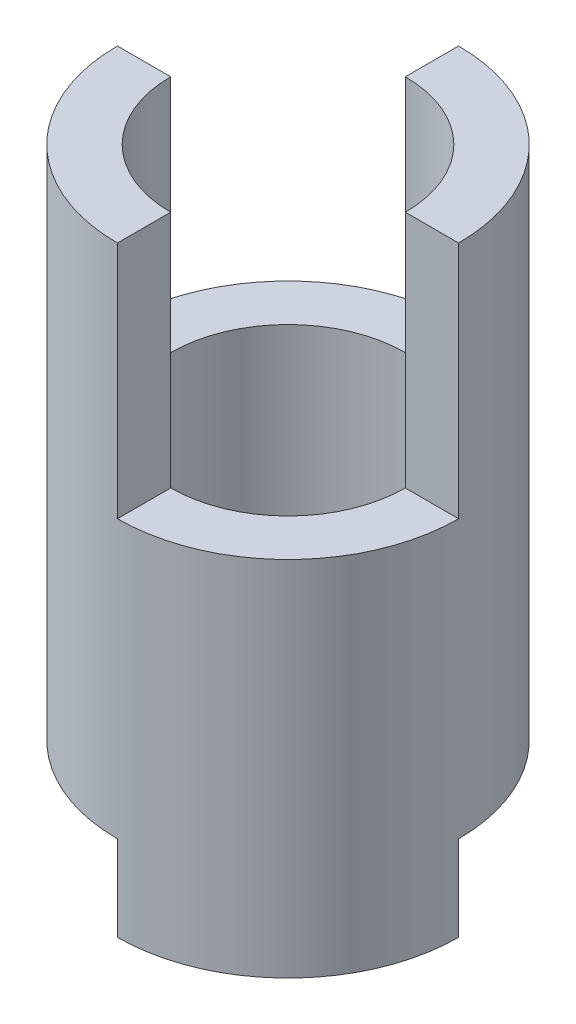
from build123d import *

# Parameters (mm, degrees)
SCHIZZO1_R                   = 4
SCHIZZO1_R_2                 = 2.75
ESTRUSIONE_ESTRUSIONE2_DEPTH = 14.1
TAGLIO_ESTRUSIONE1_DEPTH     = 5.6
TAGLIO_ESTRUSIONE2_DEPTH     = 2


with BuildPart() as part:
    # Schizzo1 → Estrusione-Estrusione2 (new body)
    with BuildSketch(Plane(origin=(0, 0, 0), x_dir=(1, 0, 0), z_dir=(0, 1, 0))):
        Circle(SCHIZZO1_R)
        Circle(SCHIZZO1_R_2, mode=Mode.SUBTRACT)
    extrude(amount=ESTRUSIONE_ESTRUSIONE2_DEPTH)

    # Schizzo2 → Taglio-Estrusione1 (cut)
    with BuildSketch(Plane(origin=(0, 14.1, 0), x_dir=(1, 0, 0), z_dir=(0, 1, 0))):
        with BuildLine():
            Line((0, 2.75), (0, 4))
            ThreePointArc((0, 4), (-2.828427125, 2.828427125), (-4, 0))
            Line((-4, 0), (-2.75, 0))
            ThreePointArc((-2.75, 0), (-1.944543648, 1.944543648), (0, 2.75))
        make_face()
        with BuildLine():
            Line((2.75, 0), (4, 0))
            ThreePointArc((4, 0), (2.828427125, -2.828427125), (0, -4))
            Line((0, -4), (0, -2.75))
            ThreePointArc((0, -2.75), (1.944543648, -1.944543648), (2.75, 0))
        make_face()
    extrude(amount=-TAGLIO_ESTRUSIONE1_DEPTH, mode=Mode.SUBTRACT)

    # Schizzo3 → Taglio-Estrusione2 (cut)
    with BuildSketch(Plane.XZ):
        with BuildLine():
            Line((0, 2.75), (0, 4))
            ThreePointArc((0, 4), (-2.828427125, 2.828427125), (-4, 0))
            Line((-4, 0), (-2.75, 0))
            ThreePointArc((-2.75, 0), (-1.944543648, 1.944543648), (0, 2.75))
        make_face()
        with BuildLine():
            Line((2.75, 0), (4, 0))
            ThreePointArc((4, 0), (2.828427125, -2.828427125), (0, -4))
            Line((0, -4), (0, -2.75))
            ThreePointArc((0, -2.75), (1.944543648, -1.944543648), (2.75, 0))
        make_face()
    extrude(amount=-TAGLIO_ESTRUSIONE2_DEPTH, mode=Mode.SUBTRACT)


solid = part.part
